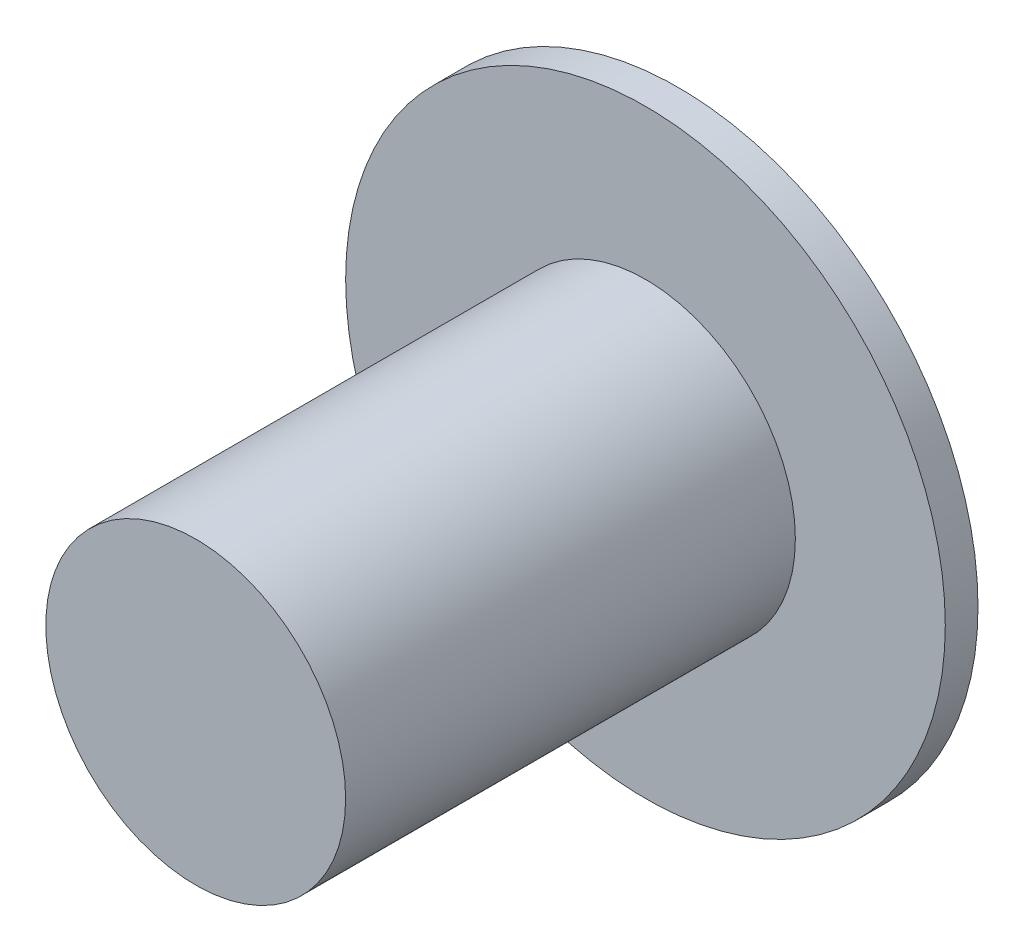
from build123d import *

# Parameters (mm, degrees)
SKETCH1_R           = 11
BOSS_EXTRUDE2_DEPTH = 5
SKETCH3_R           = 21.999999942
BOSS_EXTRUDE3_DEPTH = 2.4
SKETCH4_R           = 11
BOSS_EXTRUDE4_DEPTH = 33


with BuildPart() as part:
    # Sketch1 → Boss-Extrude2 (new body)
    with BuildSketch(Plane.XY):
        Circle(SKETCH1_R)
    extrude(amount=BOSS_EXTRUDE2_DEPTH)

    # Sketch3 → Boss-Extrude3 (add)
    with BuildSketch(Plane.XY.offset(5)):
        Circle(SKETCH3_R)
    extrude(amount=BOSS_EXTRUDE3_DEPTH)

    # Sketch4 → Boss-Extrude4 (add)
    with BuildSketch(Plane.XY.offset(7.4)):
        Circle(SKETCH4_R)
    extrude(amount=BOSS_EXTRUDE4_DEPTH)


solid = part.part
